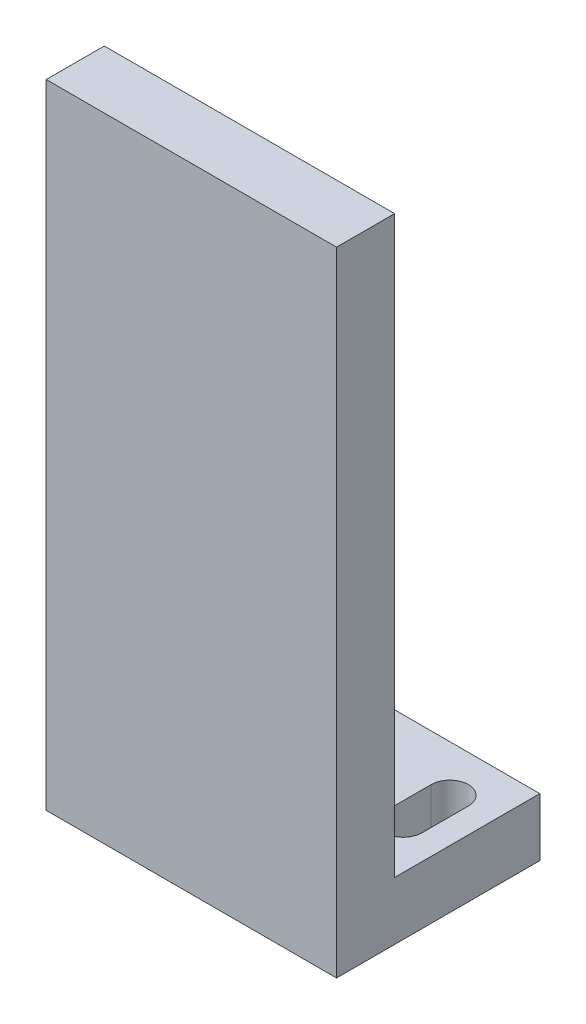
from build123d import *

# Parameters (mm, degrees)
SKETCH_1_W          = 50
SKETCH_1_H          = 35
EXTRUDE_1_DEPTH     = 109
SKETCH_2_W          = 50
SKETCH_2_H          = 25
CUT_EXTRUDE_1_DEPTH = 99
CUT_EXTRUDE_2_DEPTH = 11


with BuildPart() as part:
    # 草图1 → 凸台-拉伸1 (new body)
    with BuildSketch(Plane(origin=(0, 0, 0), x_dir=(1, 0, 0), z_dir=(0, 1, 0))):
        Rectangle(SKETCH_1_W, SKETCH_1_H)
    extrude(amount=EXTRUDE_1_DEPTH)

    # 草图2 → 切除-拉伸1 (cut)
    with BuildSketch(Plane(origin=(0, 109, 0), x_dir=(1, 0, 0), z_dir=(0, 1, 0))):
        with Locations((0, 5)):
            Rectangle(SKETCH_2_W, SKETCH_2_H)
    extrude(amount=-CUT_EXTRUDE_1_DEPTH, mode=Mode.SUBTRACT)

    # 草图3 → 切除-拉伸2 (cut, through all)
    with BuildSketch(Plane(origin=(0, 10, 0), x_dir=(1, 0, 0), z_dir=(0, 1, 0))):
        with BuildLine():
            Line((-20.7, 1.5), (-20.7, 9.5))
            ThreePointArc((-20.7, 9.5), (-17.5, 12.7), (-14.3, 9.5))
            Line((-14.3, 9.5), (-14.3, 1.5))
            ThreePointArc((-14.3, 1.5), (-17.5, -1.7), (-20.7, 1.5))
        make_face()
        with BuildLine():
            Line((20.7, 1.5), (20.7, 9.5))
            ThreePointArc((20.7, 9.5), (17.5, 12.7), (14.3, 9.5))
            Line((14.3, 9.5), (14.3, 1.5))
            ThreePointArc((14.3, 1.5), (17.5, -1.7), (20.7, 1.5))
        make_face()
    extrude(amount=-CUT_EXTRUDE_2_DEPTH, mode=Mode.SUBTRACT)


solid = part.part
